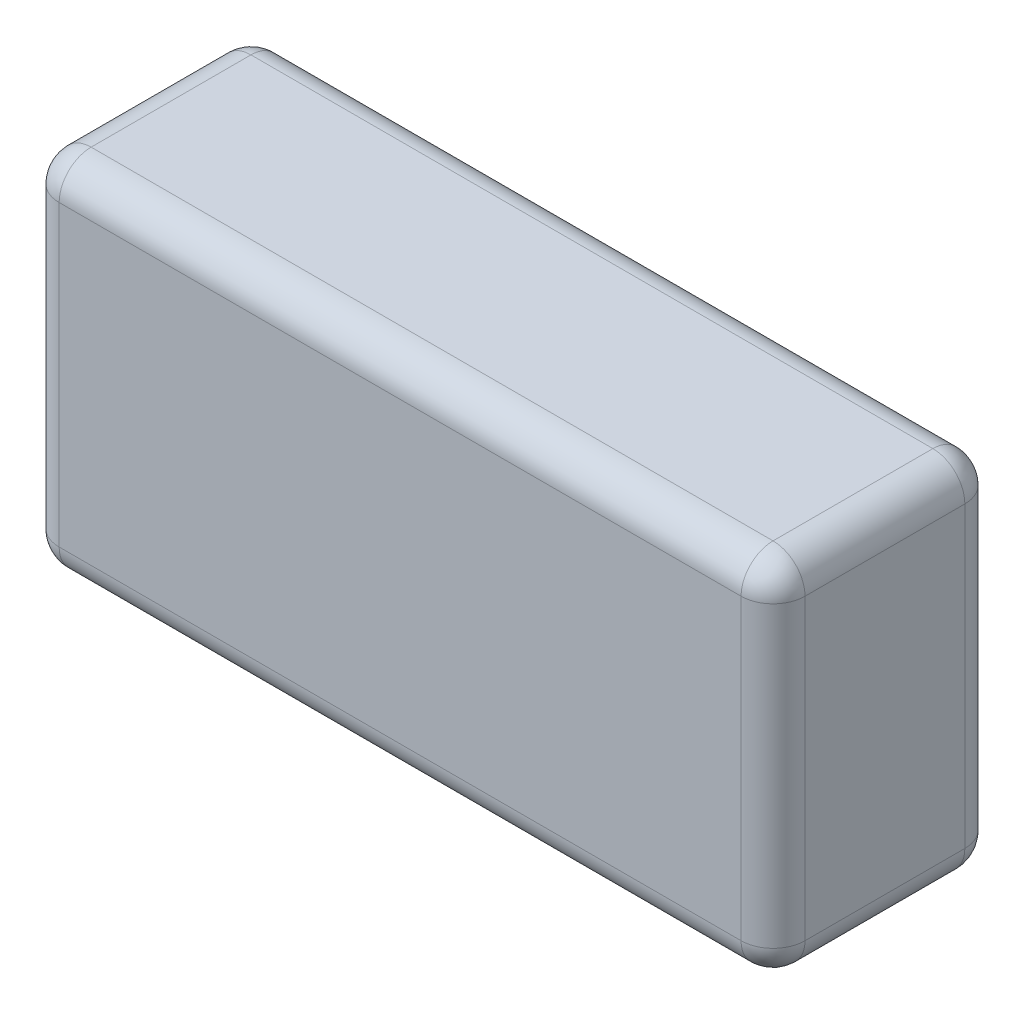
from build123d import *

# Parameters (mm, degrees)
SKETCH_1_W      = 70
SKETCH_1_H      = 21
EXTRUDE_1_DEPTH = 17
FILLET_1_R      = 3


with BuildPart() as part:
    # 草图1 → 凸台-拉伸1 (new body, symmetric)
    with BuildSketch(Plane(origin=(0, 0, 0), x_dir=(1, 0, 0), z_dir=(0, 1, 0))):
        Rectangle(SKETCH_1_W, SKETCH_1_H)
    extrude(amount=EXTRUDE_1_DEPTH, both=True)

    # 圆角1
    fillet_1_edges = [part.edges().sort_by_distance(p)[0] for p in [
        (35, 17, 0),
        (0, 17, -10.5),
        (-35, 17, 0),
        (0, -17, -10.5),
        (35, -17, 0),
        (0, -17, 10.5),
        (-35, -17, 0),
        (0, 17, 10.5),
        (-35, 0, -10.5),
        (35, 0, -10.5),
        (35, 0, 10.5),
        (-35, 0, 10.5),
    ]]
    fillet(fillet_1_edges, radius=FILLET_1_R)


solid = part.part
